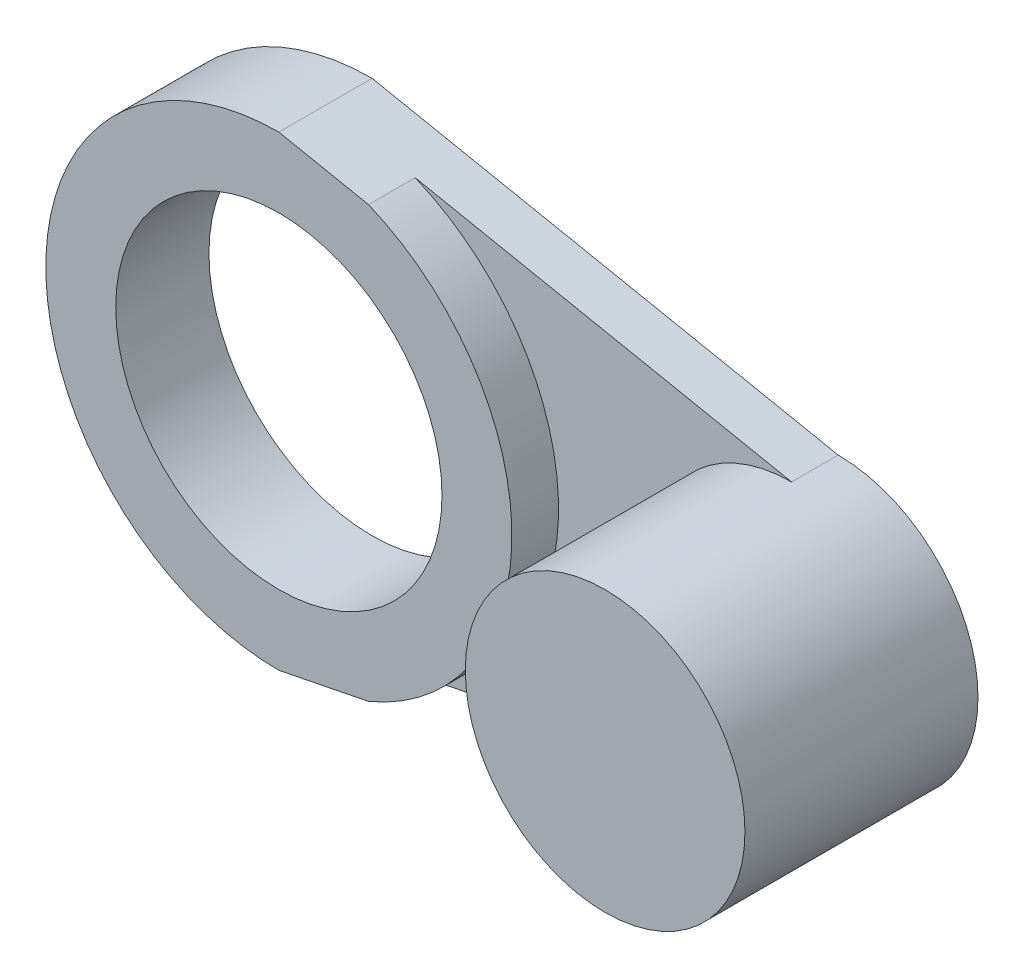
from build123d import *

# Parameters (mm, degrees)
BOSS_EXTRUDE1_DEPTH      = 5
SKETCH1_3_R              = 15
BOSS_EXTRUDE2_DEPTH      = 20
BOSS_EXTRUDE2_DEPTH_BACK = 5
SKETCH1_4_R              = 17.5
BOSS_EXTRUDE3_DEPTH      = 5
BOSS_EXTRUDE3_DEPTH_BACK = 5


with BuildPart() as part:
    # Sketch1 → Boss-Extrude1 (new body)
    with BuildSketch(Plane.XY):
        with BuildLine():
            Line((50, 15), (9.615384615, 23.076923077))
            ThreePointArc((9.615384615, 23.076923077), (20.801257358, 13.867504906), (25, 0))
            ThreePointArc((25, 0), (20.801257358, -13.867504906), (9.615384615, -23.076923077))
            Line((9.615384615, -23.076923077), (50, -15))
            ThreePointArc((50, -15), (35, 0), (50, 15))
        make_face()
    extrude(amount=-BOSS_EXTRUDE1_DEPTH)

    # Sketch1_3 → Boss-Extrude2 (add, two sides)
    with BuildSketch(Plane.XY) as boss_extrude2_sk:
        with Locations((50, 0)):
            Circle(SKETCH1_3_R)
    extrude(amount=BOSS_EXTRUDE2_DEPTH)
    extrude(boss_extrude2_sk.sketch, amount=-BOSS_EXTRUDE2_DEPTH_BACK)

    # Sketch1_4 → Boss-Extrude3 (add, two sides)
    with BuildSketch(Plane.XY) as boss_extrude3_sk:
        with BuildLine():
            Line((9.615384615, 23.076923077), (0, 25))
            ThreePointArc((0, 25), (-25, 0), (0, -25))
            Line((0, -25), (9.615384615, -23.076923077))
            ThreePointArc((9.615384615, -23.076923077), (20.801257358, -13.867504906), (25, 0))
            ThreePointArc((25, 0), (20.801257358, 13.867504906), (9.615384615, 23.076923077))
        make_face()
        Circle(SKETCH1_4_R, mode=Mode.SUBTRACT)
    extrude(amount=BOSS_EXTRUDE3_DEPTH)
    extrude(boss_extrude3_sk.sketch, amount=-BOSS_EXTRUDE3_DEPTH_BACK)


solid = part.part
